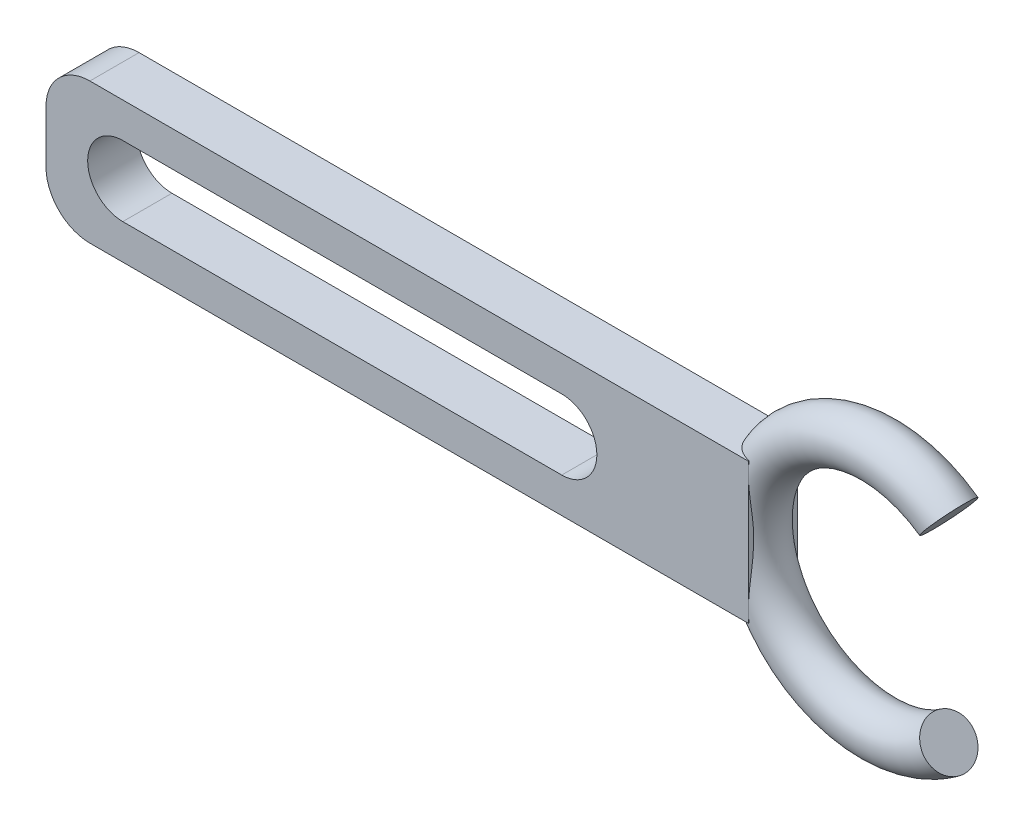
from build123d import *

# Parameters (mm, degrees)
ESBO_O2_R                  = 2.8
CORTE_EXTRUS_O1_DEPTH      = 10
CORTE_EXTRUS_O1_DEPTH_BACK = 10
RESSALTO_EXTRUS_O1_START   = -12
ESBO_O5_W                  = 5.6
ESBO_O5_H                  = 16
RESSALTO_EXTRUS_O1_DEPTH   = 80
FILETE1_R                  = 5
CORTE_EXTRUS_O2_DEPTH      = 19


with BuildPart() as part:
    # Esboço2 → Revolução1 (revolve)
    with BuildSketch(Plane(origin=(0, 0, 0), x_dir=(1, 0, 0), z_dir=(0, 1, 0))):
        with Locations((13.75, 0)):
            Circle(ESBO_O2_R)
    revolve(axis=Axis((0, 0, 0), (0, 0, -1)))

    # Esboço3 → Corte-extrusão1 (cut, two sides: drawn at the far end of the back side and taken through both)
    with BuildSketch(Plane.XY.offset(-CORTE_EXTRUS_O1_DEPTH_BACK)):
        Polygon((-1.202746457, 0), (18.876681975, 24.24777346), (18.876681975, -24.24777346), align=None)
    extrude(amount=CORTE_EXTRUS_O1_DEPTH + CORTE_EXTRUS_O1_DEPTH_BACK, mode=Mode.SUBTRACT)

    # Esboço5 → Ressalto-extrusão1 (add)
    with BuildSketch(Plane(origin=(0, 0, 0), x_dir=(0, 0, -1), z_dir=(1, 0, 0)).offset(RESSALTO_EXTRUS_O1_START)):
        Rectangle(ESBO_O5_W, ESBO_O5_H)
    extrude(amount=-RESSALTO_EXTRUS_O1_DEPTH)

    # Filete1
    filete1_edges = [part.edges().sort_by_distance(p)[0] for p in [
        (-92, 8, 0),
        (-92, -8, 0),
    ]]
    fillet(filete1_edges, radius=FILETE1_R)

    # Esboço7 → Corte-extrusão2 (cut)
    with BuildSketch(Plane(origin=(0, 0, -2.8), x_dir=(-1, 0, 0), z_dir=(0, 0, -1))):
        with BuildLine():
            Line((33.254278711, 4), (83.254278711, 4))
            ThreePointArc((83.254278711, 4), (87.254278711, 0), (83.254278711, -4))
            Line((83.254278711, -4), (33.254278711, -4))
            ThreePointArc((33.254278711, -4), (29.254278711, 0), (33.254278711, 4))
        make_face()
    extrude(amount=-CORTE_EXTRUS_O2_DEPTH, mode=Mode.SUBTRACT)


solid = part.part
